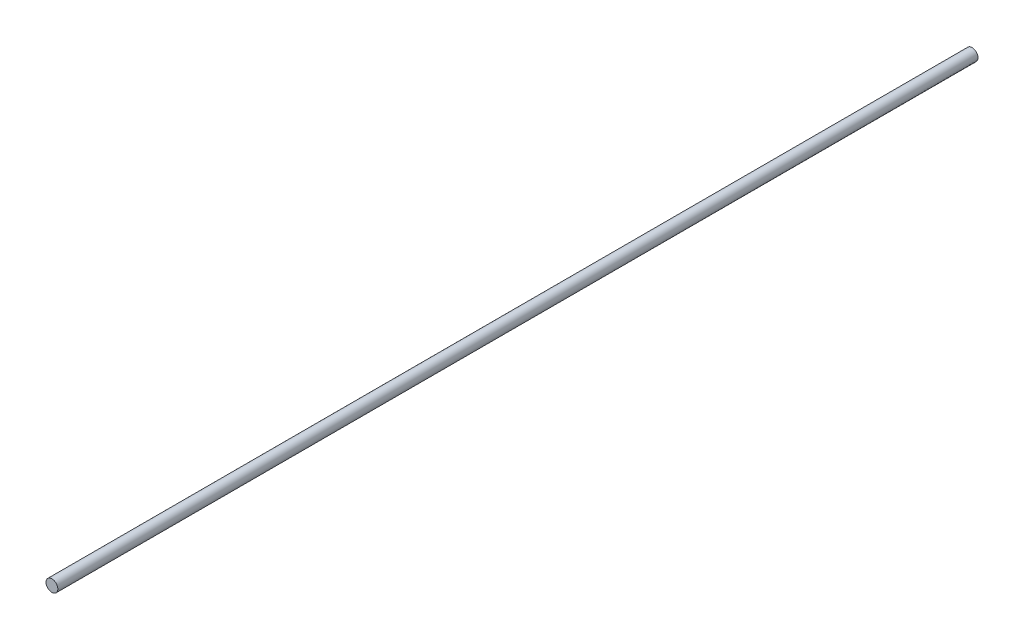
from build123d import *

# Parameters (mm, degrees)
SKETCH_1_R      = 0.45
EXTRUDE_1_DEPTH = 70


with BuildPart() as part:
    # 草图1 → 凸台-拉伸1 (new body)
    with BuildSketch(Plane.XY):
        Circle(SKETCH_1_R)
    extrude(amount=EXTRUDE_1_DEPTH)


solid = part.part
